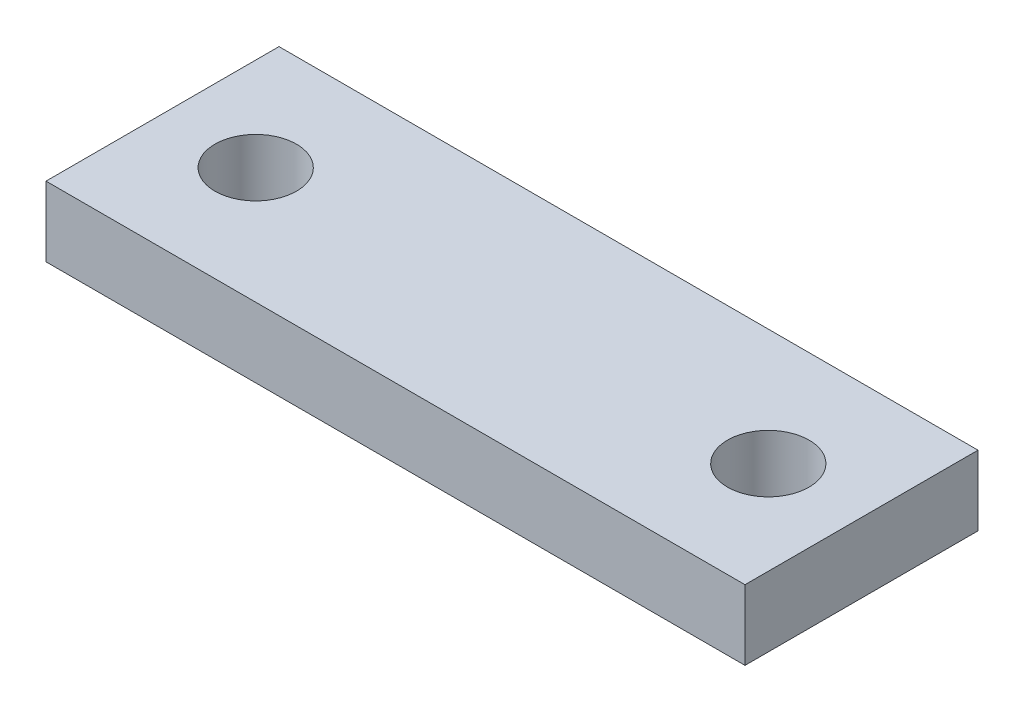
from build123d import *

# Parameters (mm, degrees)
SKETCH1_W           = 30
SKETCH1_H           = 10
SKETCH1_R           = 1.75
BOSS_EXTRUDE1_DEPTH = 3


with BuildPart() as part:
    # Sketch1 → Boss-Extrude1 (new body)
    with BuildSketch(Plane(origin=(0, 0, 0), x_dir=(1, 0, 0), z_dir=(0, 1, 0))):
        with Locations((15, 5)):
            Rectangle(SKETCH1_W, SKETCH1_H)
        with Locations((4, 5)):
            Circle(SKETCH1_R, mode=Mode.SUBTRACT)
        with Locations((26, 5)):
            Circle(SKETCH1_R, mode=Mode.SUBTRACT)
    extrude(amount=BOSS_EXTRUDE1_DEPTH)


solid = part.part
